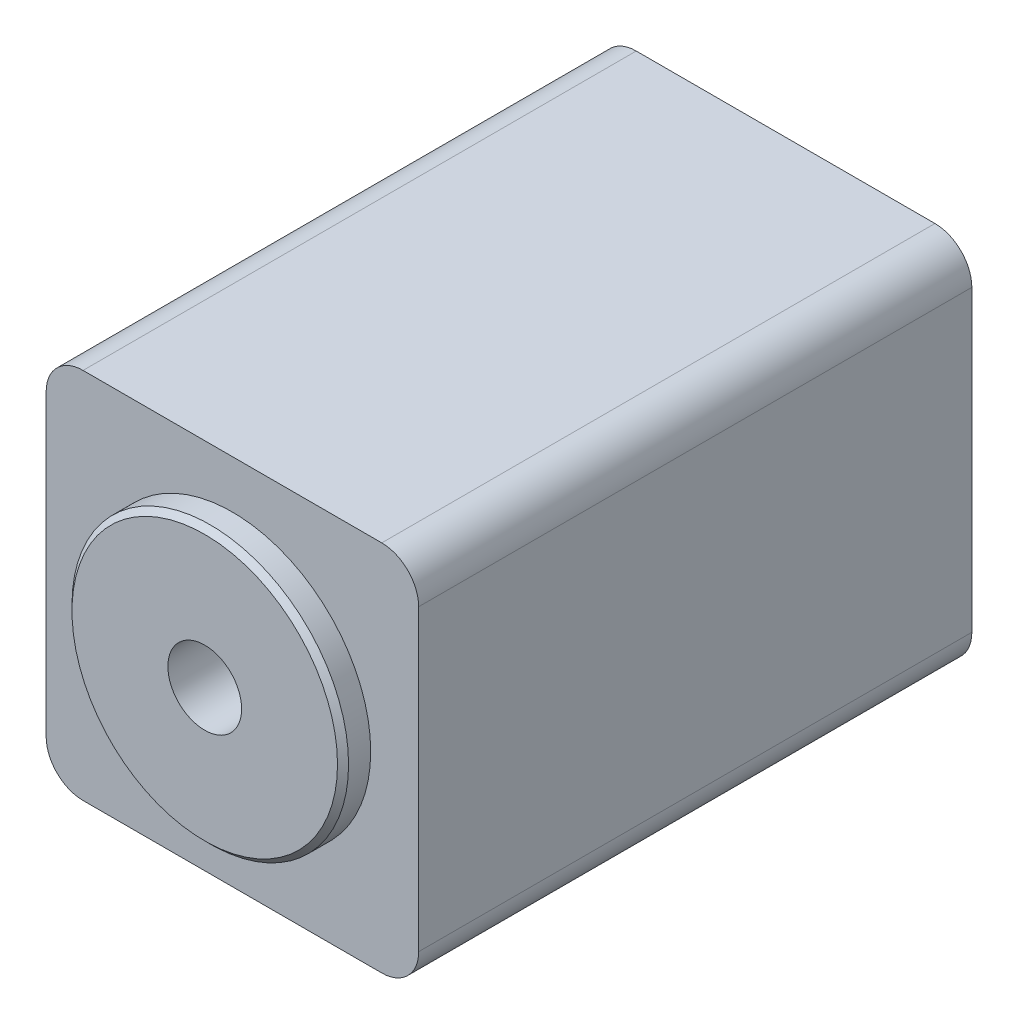
from build123d import *

# Parameters (mm, degrees)
ESQUISSE1_R             = 7.5
BOSS_EXTRU_1_DEPTH      = 1.5
ESQUISSE2_W             = 20.2
ESQUISSE2_H             = 20.2
BOSS_EXTRU_2_DEPTH      = 30
ESQUISSE6_R             = 2
ENL_V_MAT_EXTRU_1_DEPTH = 10
CHANFREIN1_SIZE         = 0.3
CONG_1_R                = 2


with BuildPart() as part:
    # Esquisse1 → Boss.-Extru.1 (new body)
    with BuildSketch(Plane.XY):
        Circle(ESQUISSE1_R)
    extrude(amount=BOSS_EXTRU_1_DEPTH)

    # Esquisse2 → Boss.-Extru.2 (add)
    with BuildSketch(Plane(origin=(0, 0, 0), x_dir=(-1, 0, 0), z_dir=(0, 0, -1))):
        Rectangle(ESQUISSE2_W, ESQUISSE2_H)
    extrude(amount=BOSS_EXTRU_2_DEPTH)

    # Esquisse6 → Enlèv. mat.-Extru.1 (cut)
    with BuildSketch(Plane.XY.offset(1.5)):
        Circle(ESQUISSE6_R)
    extrude(amount=-ENL_V_MAT_EXTRU_1_DEPTH, mode=Mode.SUBTRACT)

    # Chanfrein1
    chanfrein1_edges = [part.edges().sort_by_distance(p)[0] for p in [
        (-7.5, 0, 1.5),
    ]]
    chamfer(chanfrein1_edges, length=CHANFREIN1_SIZE)

    # Congé1
    cong_1_edges = [part.edges().sort_by_distance(p)[0] for p in [
        (-10.1, -10.1, -15),
        (-10.1, 10.1, -15),
        (10.1, 10.1, -15),
        (10.1, -10.1, -15),
    ]]
    fillet(cong_1_edges, radius=CONG_1_R)


solid = part.part
